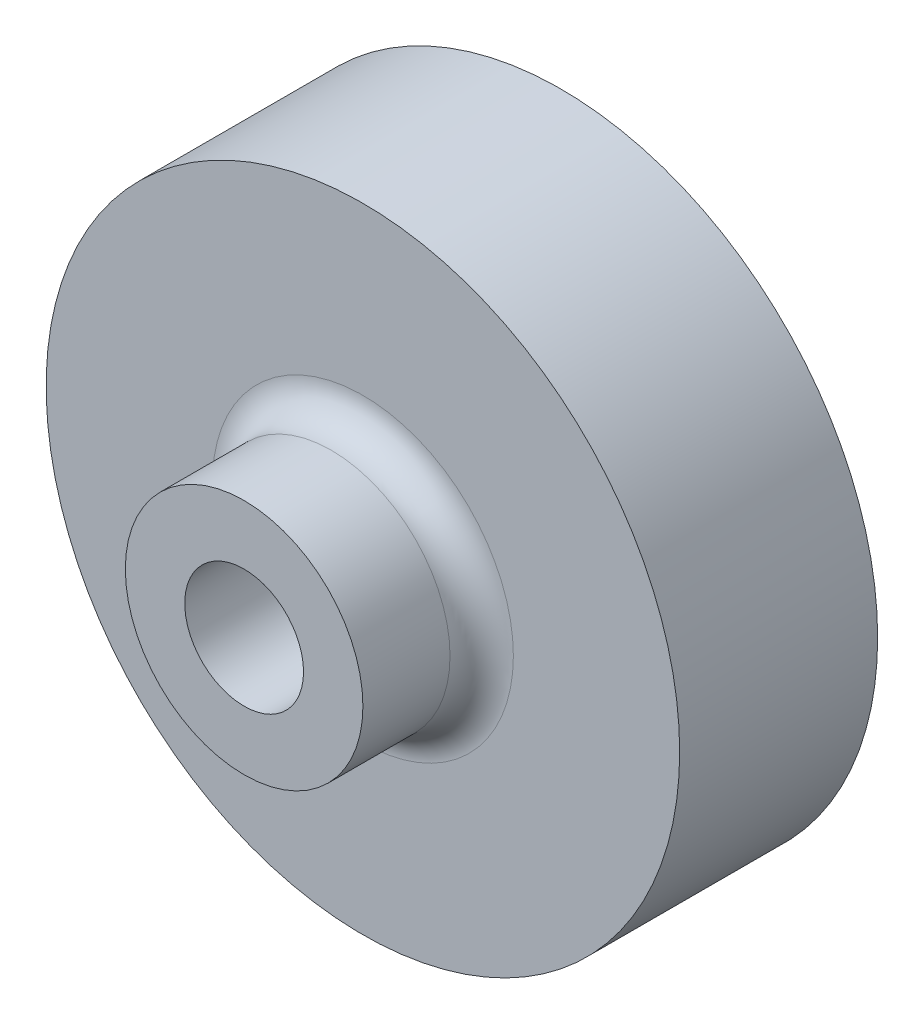
from build123d import *

# Parameters (mm, degrees)
SKETCH1_R           = 10
BOSS_EXTRUDE1_DEPTH = 1.25
SKETCH2_R           = 10
SKETCH2_R_2         = 1.875
BOSS_EXTRUDE2_DEPTH = 5
SKETCH3_R           = 3.75
SKETCH3_R_2         = 1.875
BOSS_EXTRUDE3_DEPTH = 3.75
FILLET1_R           = 1


with BuildPart() as part:
    # Sketch1 → Boss-Extrude1 (new body)
    with BuildSketch(Plane.XY):
        Circle(SKETCH1_R)
        with BuildLine():
            Line((-0.5, 1.807104037), (-0.5, -1.807104037))
            ThreePointArc((-0.5, -1.807104037), (-1.875, 0), (-0.5, 1.807104037))
        make_face(mode=Mode.SUBTRACT)
        with BuildLine():
            Line((0.5, 1.807104037), (0.5, -1.807104037))
            ThreePointArc((0.5, -1.807104037), (1.875, 0), (0.5, 1.807104037))
        make_face(mode=Mode.SUBTRACT)
    extrude(amount=BOSS_EXTRUDE1_DEPTH)

    # Sketch2 → Boss-Extrude2 (add)
    with BuildSketch(Plane.XY.offset(1.25)):
        Circle(SKETCH2_R)
        Circle(SKETCH2_R_2, mode=Mode.SUBTRACT)
    extrude(amount=BOSS_EXTRUDE2_DEPTH)

    # Sketch3 → Boss-Extrude3 (add)
    with BuildSketch(Plane.XY.offset(6.25)):
        Circle(SKETCH3_R)
        Circle(SKETCH3_R_2, mode=Mode.SUBTRACT)
    extrude(amount=BOSS_EXTRUDE3_DEPTH)

    # Fillet1
    fillet1_edges = [part.edges().sort_by_distance(p)[0] for p in [
        (-3.75, 0, 6.25),
    ]]
    fillet(fillet1_edges, radius=FILLET1_R)


solid = part.part
